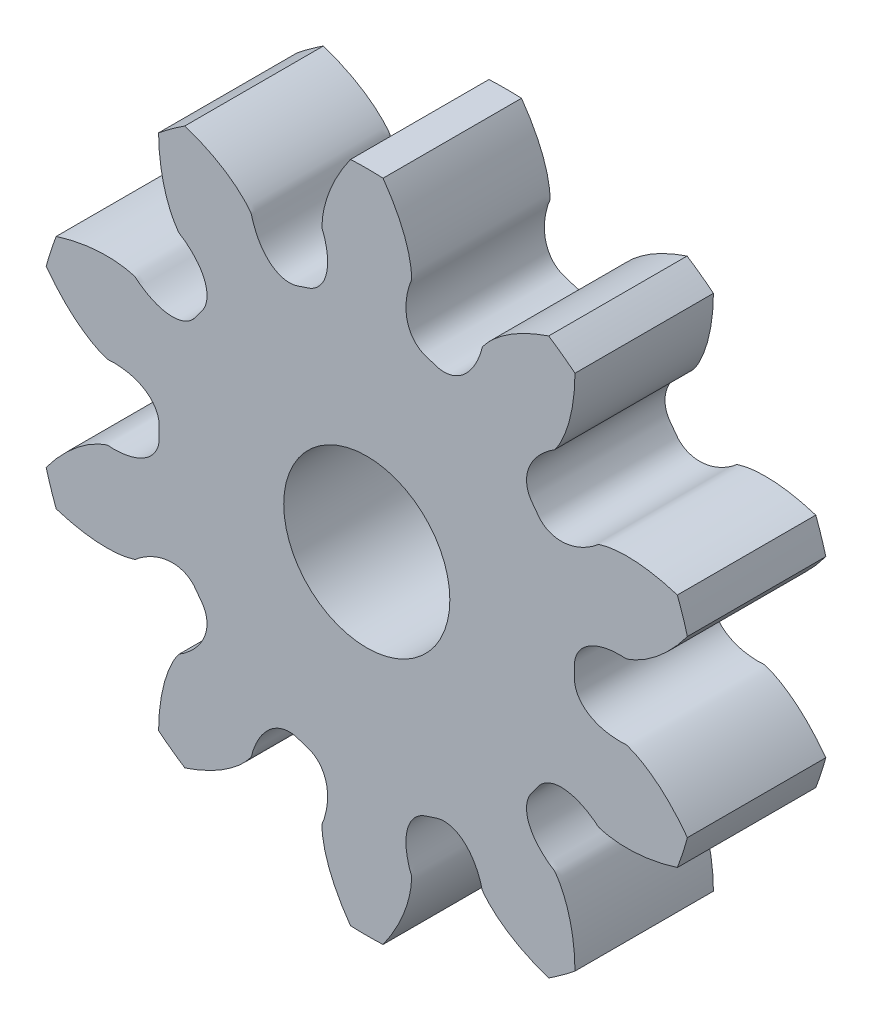
from build123d import *

# Parameters (mm, degrees)
SKETCHREVOLVEPLANET_REVOLVING_FOLLOWER01_W     = 2.5
SKETCHREVOLVEPLANET_REVOLVING_FOLLOWER01_H     = 5.99999991
TOOTHEXTRUDECUTPLANET_REVOLVING_FOLLOWER_DEPTH = 9.576858273
PATTERNPLANET_REVOLVING_FOLLOWER01_COUNT       = 10
BOREREVOLVESKETCH_W                            = 3.5
BOREREVOLVESKETCH_H                            = 1.5


with BuildPart() as part:
    # SketchRevolvePlanet_Revolving_Follower01 → Planet_Revolving_Follower01 (revolve)
    with BuildSketch(Plane(origin=(0, 0, 0), x_dir=(0, 0, -1), z_dir=(1, 0, 0))):
        with Locations((0, 2.999999955)):
            Rectangle(SKETCHREVOLVEPLANET_REVOLVING_FOLLOWER01_W, SKETCHREVOLVEPLANET_REVOLVING_FOLLOWER01_H)
    revolve(axis=Axis((0, 0, 0), (0, 0, -1)))

    # SketchToothPlanet_Revolving_Follower01 → ToothExtrudeCutPlanet_Revolving_Follower (cut, symmetric)
    with BuildSketch(Plane.XY):
        with BuildLine():
            ThreePointArc((5.827826991, 1.624478829), (6.049999909, 0), (5.827826991, -1.624478829))
            add(Edge.make_bspline(
                [(5.827826991, -1.624478829), (5.771143863, -1.544652998), (5.683869381, -1.431218278), (5.561767391, -1.291505241), (5.473999632, -1.198932917), (5.388096026, -1.115382264), (5.30463471, -1.040541109), (5.224171225, -0.974065559), (5.147236934, -0.915580878), (5.074337314, -0.864685246), (5.005951099, -0.820943339), (4.942526966, -0.783913624), (4.884488441, -0.753067445), (4.832213147, -0.72805088), (4.786091976, -0.707883702), (4.737109221, -0.689998144), (4.675738033, -0.664320556), (4.60707096, -0.677916026), (4.544843, -0.675498403), (4.495594974, -0.673884594), (4.447541906, -0.670193868), (4.400627164, -0.665071405), (4.354875648, -0.658363115), (4.310287964, -0.650114628), (4.266868323, -0.640310377), (4.224618012, -0.628939491), (4.183538237, -0.615976478), (4.143631114, -0.601383794), (4.104901961, -0.585108475), (4.067362371, -0.567080221), (4.031034554, -0.547209233), (3.995957274, -0.525384712), (3.962193714, -0.501474514), (3.929841546, -0.475326968), (3.899045169, -0.446776252), (3.870009421, -0.415653096), (3.843013416, -0.381802818), (3.818420097, -0.345112375), (3.796681307, -0.305546281), (3.77831398, -0.263189943), (3.76391178, -0.218287923), (3.753920319, -0.171285587), (3.749749507, -0.12827658), (3.748177576, -0.071062888), (3.751338313, 0), (3.748177576, 0.071062888), (3.749749507, 0.12827658), (3.753920319, 0.171285587), (3.76391178, 0.218287923), (3.77831398, 0.263189943), (3.796681307, 0.305546281), (3.818420097, 0.345112375), (3.843013416, 0.381802818), (3.870009421, 0.415653096), (3.899045169, 0.446776252), (3.929841546, 0.475326968), (3.962193714, 0.501474514), (3.995957274, 0.525384712), (4.031034554, 0.547209233), (4.067362371, 0.567080221), (4.104901961, 0.585108475), (4.143631114, 0.601383794), (4.183538237, 0.615976478), (4.224618012, 0.628939491), (4.266868323, 0.640310377), (4.310287964, 0.650114628), (4.354875648, 0.658363115), (4.400627164, 0.665071405), (4.447541906, 0.670193868), (4.495594974, 0.673884594), (4.544843, 0.675498403), (4.60707096, 0.677916026), (4.675738033, 0.664320556), (4.737109221, 0.689998144), (4.786091976, 0.707883702), (4.832213147, 0.72805088), (4.884488441, 0.753067445), (4.942526966, 0.783913624), (5.005951099, 0.820943339), (5.074337314, 0.864685246), (5.147236934, 0.915580878), (5.224171225, 0.974065559), (5.30463471, 1.040541109), (5.388096026, 1.115382264), (5.473999632, 1.198932917), (5.561767391, 1.291505241), (5.683869381, 1.431218278), (5.771143863, 1.544652998), (5.827826991, 1.624478829)],
                knots=[0, 0, 0, 0, 0.051709588, 0.075523214, 0.097976061, 0.11906813, 0.138799421, 0.157169932, 0.174179665, 0.18982862, 0.204116796, 0.217044194, 0.228610813, 0.238816653, 0.247661716, 0.255145999, 0.266488168, 0.281932497, 0.29079109, 0.29945754, 0.3079389, 0.316243077, 0.32437896, 0.33235655, 0.340187113, 0.347883348, 0.355459572, 0.362931907, 0.370318475, 0.377639574, 0.384917807, 0.392178142, 0.399447816, 0.40675603, 0.414133302, 0.42161038, 0.429216569, 0.436977418, 0.444911792, 0.453028613, 0.461323803, 0.469778278, 0.478357898, 0.484105769, 0.5, 0.515894231, 0.521642102, 0.530221722, 0.538676197, 0.546971387, 0.555088208, 0.563022582, 0.570783431, 0.57838962, 0.585866698, 0.59324397, 0.600552184, 0.607821858, 0.615082193, 0.622360426, 0.629681525, 0.637068093, 0.644540428, 0.652116652, 0.659812887, 0.66764345, 0.67562104, 0.683756923, 0.6920611, 0.70054246, 0.70920891, 0.718067503, 0.733511832, 0.744854001, 0.752338284, 0.761183347, 0.771389187, 0.782955806, 0.795883204, 0.81017138, 0.825820335, 0.842830068, 0.861200579, 0.88093187, 0.902023939, 0.924476786, 0.948290412, 1, 1, 1, 1], degree=3))
        make_face()
    toothextrudecutplanet_revolving_follower = extrude(amount=TOOTHEXTRUDECUTPLANET_REVOLVING_FOLLOWER_DEPTH, both=True, mode=Mode.SUBTRACT)

    # PatternPlanet_Revolving_Follower01: ToothExtrudeCutPlanet_Revolving_Follower ×10 about axis
    patternplanet_revolving_follower01_axis = Axis((0, 0, 50), (0, 0, -1))
    for i in range(1, PATTERNPLANET_REVOLVING_FOLLOWER01_COUNT):
        add(toothextrudecutplanet_revolving_follower.rotate(patternplanet_revolving_follower01_axis, i * 360 / PATTERNPLANET_REVOLVING_FOLLOWER01_COUNT), mode=Mode.SUBTRACT)

    # BoreRevolveSketch → BoreRevolveCut (revolve, cut)
    with BuildSketch(Plane(origin=(0, 0, 0), x_dir=(0, 0, -1), z_dir=(1, 0, 0))):
        with Locations((0, 0.75)):
            Rectangle(BOREREVOLVESKETCH_W, BOREREVOLVESKETCH_H)
    revolve(axis=Axis((0, 0, 0), (0, 0, -1)), mode=Mode.SUBTRACT)


solid = part.part
